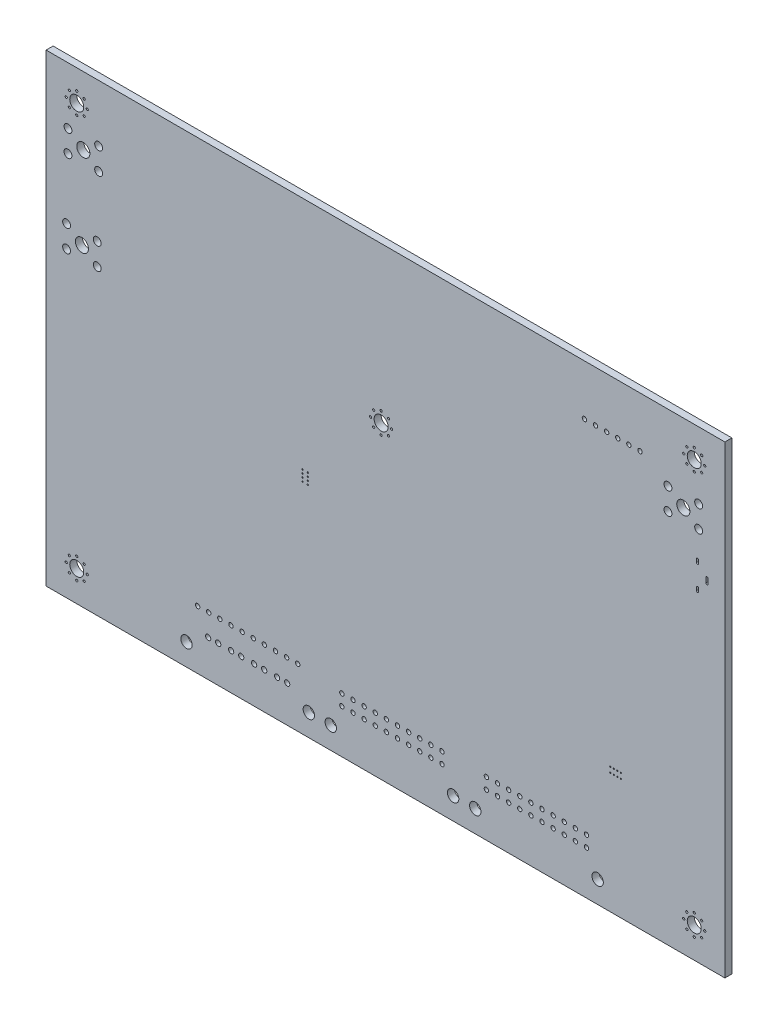
from build123d import *

# Parameters (mm, degrees)
SKETCH1_W           = 155
SKETCH1_H           = 106
SKETCH1_R           = 0.25
SKETCH1_R_2         = 1.6
SKETCH1_R_3         = 0.9
SKETCH1_R_4         = 0.5
SKETCH1_R_5         = 0.15
SKETCH1_R_6         = 1.3
SKETCH1_R_7         = 0.6
SKETCH1_R_8         = 1.5
BOSS_EXTRUDE1_DEPTH = 1.6


with BuildPart() as part:
    # Sketch1 → Boss-Extrude1 (new body)
    with BuildSketch(Plane.XY.offset(1.6)):
        with Locations((70.5, 46)):
            Rectangle(SKETCH1_W, SKETCH1_H)
        with Locations((0, 94.4)):
            Circle(SKETCH1_R, mode=Mode.SUBTRACT)
        with Locations((141, 94.4)):
            Circle(SKETCH1_R, mode=Mode.SUBTRACT)
        with Locations((143.4, 92)):
            Circle(SKETCH1_R, mode=Mode.SUBTRACT)
        with Locations((143.4, 0)):
            Circle(SKETCH1_R, mode=Mode.SUBTRACT)
        with Locations((0, 89.6)):
            Circle(SKETCH1_R, mode=Mode.SUBTRACT)
        with Locations((141, 89.6)):
            Circle(SKETCH1_R, mode=Mode.SUBTRACT)
        with Locations((2.4, 92)):
            Circle(SKETCH1_R, mode=Mode.SUBTRACT)
        with Locations((1.697056, 90.302944)):
            Circle(SKETCH1_R, mode=Mode.SUBTRACT)
        with Locations((0, 92)):
            Circle(SKETCH1_R_2, mode=Mode.SUBTRACT)
        with Locations((-1.697056, 90.302944)):
            Circle(SKETCH1_R, mode=Mode.SUBTRACT)
        with Locations((1.697056, 93.697056)):
            Circle(SKETCH1_R, mode=Mode.SUBTRACT)
        with Locations((-1.697056, 93.697056)):
            Circle(SKETCH1_R, mode=Mode.SUBTRACT)
        with Locations((-2.4, 92)):
            Circle(SKETCH1_R, mode=Mode.SUBTRACT)
        with Locations((138.6, 92)):
            Circle(SKETCH1_R, mode=Mode.SUBTRACT)
        with Locations((142.697056, 93.697056)):
            Circle(SKETCH1_R, mode=Mode.SUBTRACT)
        with Locations((139.302944, 93.697056)):
            Circle(SKETCH1_R, mode=Mode.SUBTRACT)
        with Locations((142.697056, 90.302944)):
            Circle(SKETCH1_R, mode=Mode.SUBTRACT)
        with Locations((139.302944, 90.302944)):
            Circle(SKETCH1_R, mode=Mode.SUBTRACT)
        with Locations((141, 92)):
            Circle(SKETCH1_R_2, mode=Mode.SUBTRACT)
        with Locations((142, 83.75)):
            Circle(SKETCH1_R_3, mode=Mode.SUBTRACT)
        with Locations((142, 78.75)):
            Circle(SKETCH1_R_3, mode=Mode.SUBTRACT)
        with Locations((135, 83.75)):
            Circle(SKETCH1_R_3, mode=Mode.SUBTRACT)
        with Locations((135, 78.75)):
            Circle(SKETCH1_R_3, mode=Mode.SUBTRACT)
        with Locations((126.08, 87.5)):
            Circle(SKETCH1_R_4, mode=Mode.SUBTRACT)
        with Locations((128.62, 87.5)):
            Circle(SKETCH1_R_4, mode=Mode.SUBTRACT)
        with Locations((51.555, 44.534)):
            Circle(SKETCH1_R_5, mode=Mode.SUBTRACT)
        with Locations((51.555, 43.734)):
            Circle(SKETCH1_R_5, mode=Mode.SUBTRACT)
        with Locations((51.555, 42.934)):
            Circle(SKETCH1_R_5, mode=Mode.SUBTRACT)
        with Locations((51.555, 45.334)):
            Circle(SKETCH1_R_5, mode=Mode.SUBTRACT)
        with Locations((5, 86)):
            Circle(SKETCH1_R_3, mode=Mode.SUBTRACT)
        with Locations((4.68, 67.02)):
            Circle(SKETCH1_R_3, mode=Mode.SUBTRACT)
        with Locations((4.68, 62.02)):
            Circle(SKETCH1_R_3, mode=Mode.SUBTRACT)
        with Locations((5, 81)):
            Circle(SKETCH1_R_3, mode=Mode.SUBTRACT)
        with Locations((-2, 81)):
            Circle(SKETCH1_R_3, mode=Mode.SUBTRACT)
        with Locations((-2, 86)):
            Circle(SKETCH1_R_3, mode=Mode.SUBTRACT)
        with Locations((-2.32, 67.02)):
            Circle(SKETCH1_R_3, mode=Mode.SUBTRACT)
        with Locations((-2.32, 62.02)):
            Circle(SKETCH1_R_3, mode=Mode.SUBTRACT)
        with Locations((52.755, 42.934)):
            Circle(SKETCH1_R_5, mode=Mode.SUBTRACT)
        with Locations((67.1, 63.5)):
            Circle(SKETCH1_R, mode=Mode.SUBTRACT)
        with Locations((52.755, 45.334)):
            Circle(SKETCH1_R_5, mode=Mode.SUBTRACT)
        with Locations((52.755, 43.734)):
            Circle(SKETCH1_R_5, mode=Mode.SUBTRACT)
        with Locations((52.755, 44.534)):
            Circle(SKETCH1_R_5, mode=Mode.SUBTRACT)
        with Locations((118.46, 87.5)):
            Circle(SKETCH1_R_4, mode=Mode.SUBTRACT)
        with Locations((121, 87.5)):
            Circle(SKETCH1_R_4, mode=Mode.SUBTRACT)
        with Locations((115.92, 87.5)):
            Circle(SKETCH1_R_4, mode=Mode.SUBTRACT)
        with Locations((71.9, 63.5)):
            Circle(SKETCH1_R, mode=Mode.SUBTRACT)
        with Locations((69.5, 65.9)):
            Circle(SKETCH1_R, mode=Mode.SUBTRACT)
        with Locations((69.5, 61.1)):
            Circle(SKETCH1_R, mode=Mode.SUBTRACT)
        with Locations((71.197056, 65.197056)):
            Circle(SKETCH1_R, mode=Mode.SUBTRACT)
        with Locations((67.802944, 65.197056)):
            Circle(SKETCH1_R, mode=Mode.SUBTRACT)
        with Locations((67.802944, 61.802944)):
            Circle(SKETCH1_R, mode=Mode.SUBTRACT)
        with Locations((69.5, 63.5)):
            Circle(SKETCH1_R_2, mode=Mode.SUBTRACT)
        with Locations((71.197056, 61.802944)):
            Circle(SKETCH1_R, mode=Mode.SUBTRACT)
        with Locations((122.65, 21.7)):
            Circle(SKETCH1_R_5, mode=Mode.SUBTRACT)
        with Locations((121.85, 21.7)):
            Circle(SKETCH1_R_5, mode=Mode.SUBTRACT)
        with Locations((123.45, 21.7)):
            Circle(SKETCH1_R_5, mode=Mode.SUBTRACT)
        with Locations((124.25, 21.7)):
            Circle(SKETCH1_R_5, mode=Mode.SUBTRACT)
        with Locations((123.54, 87.5)):
            Circle(SKETCH1_R_4, mode=Mode.SUBTRACT)
        with Locations((-2.4, 0)):
            Circle(SKETCH1_R, mode=Mode.SUBTRACT)
        with Locations((121.85, 20.5)):
            Circle(SKETCH1_R_5, mode=Mode.SUBTRACT)
        with Locations((123.45, 20.5)):
            Circle(SKETCH1_R_5, mode=Mode.SUBTRACT)
        with Locations((124.25, 20.5)):
            Circle(SKETCH1_R_5, mode=Mode.SUBTRACT)
        with Locations((122.65, 20.5)):
            Circle(SKETCH1_R_5, mode=Mode.SUBTRACT)
        with Locations((27.6, 6.36)):
            Circle(SKETCH1_R_4, mode=Mode.SUBTRACT)
        with Locations((30.14, 6.36)):
            Circle(SKETCH1_R_4, mode=Mode.SUBTRACT)
        with Locations((37.76, 6.36)):
            Circle(SKETCH1_R_4, mode=Mode.SUBTRACT)
        with Locations((35.22, 6.36)):
            Circle(SKETCH1_R_4, mode=Mode.SUBTRACT)
        with Locations((32.68, 6.36)):
            Circle(SKETCH1_R_4, mode=Mode.SUBTRACT)
        with Locations((45.38, 6.36)):
            Circle(SKETCH1_R_4, mode=Mode.SUBTRACT)
        with Locations((42.84, 6.36)):
            Circle(SKETCH1_R_4, mode=Mode.SUBTRACT)
        with Locations((40.3, 6.36)):
            Circle(SKETCH1_R_4, mode=Mode.SUBTRACT)
        with Locations((47.92, 6.36)):
            Circle(SKETCH1_R_4, mode=Mode.SUBTRACT)
        with Locations((108.78, 5.54)):
            Circle(SKETCH1_R_4, mode=Mode.SUBTRACT)
        with Locations((111.32, 5.54)):
            Circle(SKETCH1_R_4, mode=Mode.SUBTRACT)
        with Locations((113.86, 5.54)):
            Circle(SKETCH1_R_4, mode=Mode.SUBTRACT)
        with Locations((116.4, 5.54)):
            Circle(SKETCH1_R_4, mode=Mode.SUBTRACT)
        with Locations((80.86, 5.54)):
            Circle(SKETCH1_R_4, mode=Mode.SUBTRACT)
        with Locations((83.4, 5.54)):
            Circle(SKETCH1_R_4, mode=Mode.SUBTRACT)
        with Locations((93.54, 5.54)):
            Circle(SKETCH1_R_4, mode=Mode.SUBTRACT)
        with Locations((98.62, 5.54)):
            Circle(SKETCH1_R_4, mode=Mode.SUBTRACT)
        with Locations((96.08, 5.54)):
            Circle(SKETCH1_R_4, mode=Mode.SUBTRACT)
        with Locations((101.16, 5.54)):
            Circle(SKETCH1_R_4, mode=Mode.SUBTRACT)
        with Locations((103.7, 5.54)):
            Circle(SKETCH1_R_4, mode=Mode.SUBTRACT)
        with Locations((106.24, 5.54)):
            Circle(SKETCH1_R_4, mode=Mode.SUBTRACT)
        with Locations((73.24, 5.54)):
            Circle(SKETCH1_R_4, mode=Mode.SUBTRACT)
        with Locations((75.78, 5.54)):
            Circle(SKETCH1_R_4, mode=Mode.SUBTRACT)
        with Locations((78.32, 5.54)):
            Circle(SKETCH1_R_4, mode=Mode.SUBTRACT)
        with Locations((68.16, 5.54)):
            Circle(SKETCH1_R_4, mode=Mode.SUBTRACT)
        with Locations((70.7, 5.54)):
            Circle(SKETCH1_R_4, mode=Mode.SUBTRACT)
        with Locations((65.62, 5.54)):
            Circle(SKETCH1_R_4, mode=Mode.SUBTRACT)
        with Locations((50.46, 6.36)):
            Circle(SKETCH1_R_4, mode=Mode.SUBTRACT)
        with Locations((60.54, 5.54)):
            Circle(SKETCH1_R_4, mode=Mode.SUBTRACT)
        with Locations((63.08, 5.54)):
            Circle(SKETCH1_R_4, mode=Mode.SUBTRACT)
        with Locations((-1.697056, -1.697056)):
            Circle(SKETCH1_R, mode=Mode.SUBTRACT)
        Circle(SKETCH1_R_2, mode=Mode.SUBTRACT)
        with Locations((-1.697056, 1.697056)):
            Circle(SKETCH1_R, mode=Mode.SUBTRACT)
        with Locations((73.24, 3)):
            Circle(SKETCH1_R_4, mode=Mode.SUBTRACT)
        with Locations((91, -2)):
            Circle(SKETCH1_R_6, mode=Mode.SUBTRACT)
        with Locations((85.94, -2)):
            Circle(SKETCH1_R_6, mode=Mode.SUBTRACT)
        with Locations((106.24, 3)):
            Circle(SKETCH1_R_4, mode=Mode.SUBTRACT)
        with Locations((108.78, 3)):
            Circle(SKETCH1_R_4, mode=Mode.SUBTRACT)
        with Locations((93.54, 3)):
            Circle(SKETCH1_R_4, mode=Mode.SUBTRACT)
        with Locations((98.62, 3)):
            Circle(SKETCH1_R_4, mode=Mode.SUBTRACT)
        with Locations((96.08, 3)):
            Circle(SKETCH1_R_4, mode=Mode.SUBTRACT)
        with Locations((101.16, 3)):
            Circle(SKETCH1_R_4, mode=Mode.SUBTRACT)
        with Locations((103.7, 3)):
            Circle(SKETCH1_R_4, mode=Mode.SUBTRACT)
        with Locations((83.4, 3)):
            Circle(SKETCH1_R_4, mode=Mode.SUBTRACT)
        with Locations((80.86, 3)):
            Circle(SKETCH1_R_4, mode=Mode.SUBTRACT)
        with Locations((78.32, 3)):
            Circle(SKETCH1_R_4, mode=Mode.SUBTRACT)
        with Locations((75.78, 3)):
            Circle(SKETCH1_R_4, mode=Mode.SUBTRACT)
        with Locations((111.32, 3)):
            Circle(SKETCH1_R_4, mode=Mode.SUBTRACT)
        with Locations((141, -2.4)):
            Circle(SKETCH1_R, mode=Mode.SUBTRACT)
        with Locations((118.94, -2)):
            Circle(SKETCH1_R_6, mode=Mode.SUBTRACT)
        with Locations((116.4, 3)):
            Circle(SKETCH1_R_4, mode=Mode.SUBTRACT)
        with Locations((113.86, 3)):
            Circle(SKETCH1_R_4, mode=Mode.SUBTRACT)
        with Locations((141, 2.4)):
            Circle(SKETCH1_R, mode=Mode.SUBTRACT)
        with Locations((138.6, 0)):
            Circle(SKETCH1_R, mode=Mode.SUBTRACT)
        with Locations((139.302944, -1.697056)):
            Circle(SKETCH1_R, mode=Mode.SUBTRACT)
        with Locations((142.697056, 1.697056)):
            Circle(SKETCH1_R, mode=Mode.SUBTRACT)
        with Locations((142.697056, -1.697056)):
            Circle(SKETCH1_R, mode=Mode.SUBTRACT)
        with Locations((139.302944, 1.697056)):
            Circle(SKETCH1_R, mode=Mode.SUBTRACT)
        with Locations((141, 0)):
            Circle(SKETCH1_R_2, mode=Mode.SUBTRACT)
        with Locations((58, -2)):
            Circle(SKETCH1_R_6, mode=Mode.SUBTRACT)
        with Locations((63.08, 3)):
            Circle(SKETCH1_R_4, mode=Mode.SUBTRACT)
        with Locations((60.54, 3)):
            Circle(SKETCH1_R_4, mode=Mode.SUBTRACT)
        with Locations((68.16, 3)):
            Circle(SKETCH1_R_4, mode=Mode.SUBTRACT)
        with Locations((65.62, 3)):
            Circle(SKETCH1_R_4, mode=Mode.SUBTRACT)
        with Locations((70.7, 3)):
            Circle(SKETCH1_R_4, mode=Mode.SUBTRACT)
        with Locations((42.805, 1.36)):
            Circle(SKETCH1_R_7, mode=Mode.SUBTRACT)
        with Locations((45.755, 1.36)):
            Circle(SKETCH1_R_7, mode=Mode.SUBTRACT)
        with Locations((40.505, 1.36)):
            Circle(SKETCH1_R_7, mode=Mode.SUBTRACT)
        with Locations((37.555, 1.36)):
            Circle(SKETCH1_R_7, mode=Mode.SUBTRACT)
        with Locations((48.055, 1.36)):
            Circle(SKETCH1_R_7, mode=Mode.SUBTRACT)
        with Locations((53, -2)):
            Circle(SKETCH1_R_6, mode=Mode.SUBTRACT)
        with Locations((30.005, 1.36)):
            Circle(SKETCH1_R_7, mode=Mode.SUBTRACT)
        with Locations((32.305, 1.36)):
            Circle(SKETCH1_R_7, mode=Mode.SUBTRACT)
        with Locations((35.255, 1.36)):
            Circle(SKETCH1_R_7, mode=Mode.SUBTRACT)
        with Locations((25.06, -2)):
            Circle(SKETCH1_R_6, mode=Mode.SUBTRACT)
        with Locations((2.4, 0)):
            Circle(SKETCH1_R, mode=Mode.SUBTRACT)
        with Locations((1.697056, -1.697056)):
            Circle(SKETCH1_R, mode=Mode.SUBTRACT)
        with Locations((0, -2.4)):
            Circle(SKETCH1_R, mode=Mode.SUBTRACT)
        with Locations((1.697056, 1.697056)):
            Circle(SKETCH1_R, mode=Mode.SUBTRACT)
        with Locations((0, 2.4)):
            Circle(SKETCH1_R, mode=Mode.SUBTRACT)
        with Locations((138.5, 81.25)):
            Circle(SKETCH1_R_8, mode=Mode.SUBTRACT)
        with Locations((1.5, 83.5)):
            Circle(SKETCH1_R_8, mode=Mode.SUBTRACT)
        with Locations((1.18, 64.52)):
            Circle(SKETCH1_R_8, mode=Mode.SUBTRACT)
        with BuildLine():
            Line((143.65, 68.95), (143.65, 70.05))
            ThreePointArc((143.65, 70.05), (143.9, 70.3), (144.15, 70.05))
            Line((144.15, 70.05), (144.15, 68.95))
            ThreePointArc((144.15, 68.95), (143.9, 68.7), (143.65, 68.95))
        make_face(mode=Mode.SUBTRACT)
        with BuildLine():
            Line((141.5, 66.35), (141.5, 67.05))
            ThreePointArc((141.5, 67.05), (141.75, 67.3), (142, 67.05))
            Line((142, 67.05), (142, 66.35))
            ThreePointArc((142, 66.35), (141.75, 66.1), (141.5, 66.35))
        make_face(mode=Mode.SUBTRACT)
        with BuildLine():
            Line((141.5, 71.95), (141.5, 72.65))
            ThreePointArc((141.5, 72.65), (141.75, 72.9), (142, 72.65))
            Line((142, 72.65), (142, 71.95))
            ThreePointArc((142, 71.95), (141.75, 71.7), (141.5, 71.95))
        make_face(mode=Mode.SUBTRACT)
    extrude(amount=-BOSS_EXTRUDE1_DEPTH)


solid = part.part
